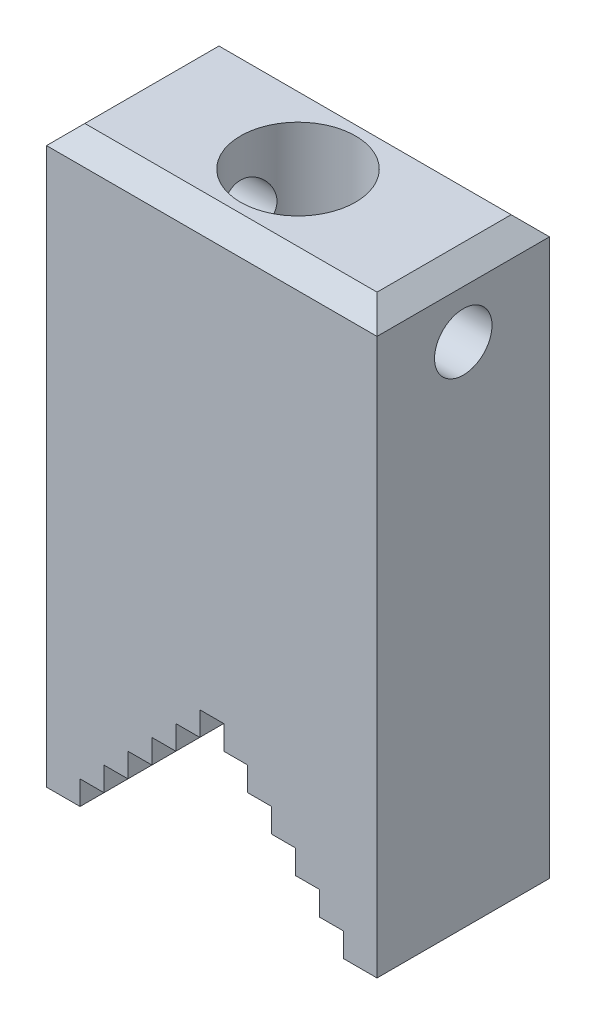
from build123d import *

# Parameters (mm, degrees)
BOSS_EXTRUDE1_DEPTH = 18
SKETCH3_R           = 3
CUT_EXTRUDE1_DEPTH  = 35.5
CHAMFER2_SIZE       = 2


with BuildPart() as part:
    # Sketch1 → Boss-Extrude1 (new body)
    with BuildSketch(Plane.XY):
        Polygon((0, 0), (3.5, 0), (3.5, 2.5), (6, 2.5), (6, 5), (8.5, 5), (8.5, 7.5), (11, 7.5), (11, 10), (13.5, 10), (13.5, 12.5), (16, 12.5), (16, 15), (18.5, 15), (18.5, 12.5), (21, 12.5), (21, 10), (23.5, 10), (23.5, 7.5), (26, 7.5), (26, 5), (28.5, 5), (28.5, 2.5), (31, 2.5), (31, 0), (34.5, 0), (34.5, 60), (0, 60), align=None)
    extrude(amount=BOSS_EXTRUDE1_DEPTH)

    # Sketch2 → Cut-Revolve1 (revolve, cut)
    with BuildSketch(Plane.XY.offset(9)):
        Polygon((11.25, 60), (11.25, 40), (17.25, 36.535898385), (17.25, 60), align=None)
    revolve(axis=Axis((17.25, 60, 9), (0, -1, 0)), mode=Mode.SUBTRACT)

    # Sketch3 → Cut-Extrude1 (cut, through all)
    with BuildSketch(Plane(origin=(34.5, 0, 0), x_dir=(0, 0, -1), z_dir=(1, 0, 0))):
        with Locations((-9, 53)):
            Circle(SKETCH3_R)
    extrude(amount=-CUT_EXTRUDE1_DEPTH, mode=Mode.SUBTRACT)

    # Chamfer2
    chamfer2_edges = [part.edges().sort_by_distance(p)[0] for p in [
        (17.25, 60, 18),
        (17.25, 60, 0),
        (0, 60, 9),
        (34.5, 60, 9),
    ]]
    chamfer(chamfer2_edges, length=CHAMFER2_SIZE)


solid = part.part
